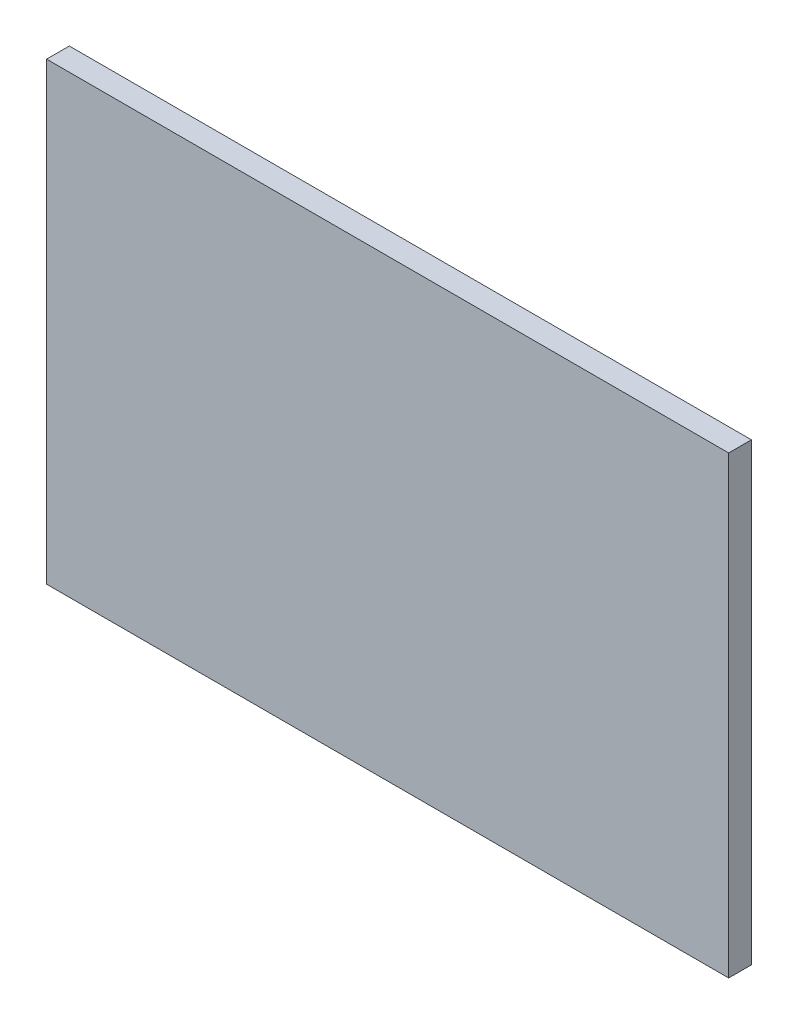
from build123d import *

# Parameters (mm, degrees)
CROQUIS1_W              = 30
CROQUIS1_H              = 20
SALIENTE_EXTRUIR1_DEPTH = 1


with BuildPart() as part:
    # Croquis1 → Saliente-Extruir1 (new body)
    with BuildSketch(Plane.XY):
        with Locations((-57.202547953, 25.032165878)):
            Rectangle(CROQUIS1_W, CROQUIS1_H)
    extrude(amount=SALIENTE_EXTRUIR1_DEPTH)


solid = part.part
